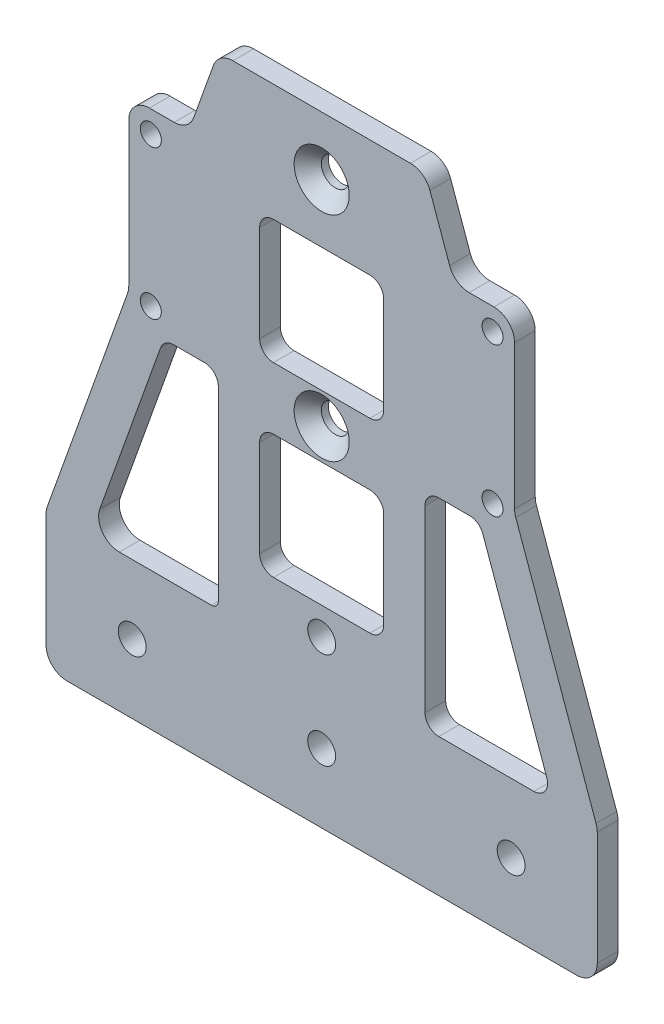
from build123d import *

# Parameters (mm, degrees)
EXTRUDE_1_DEPTH           = 1.5
SKETCH_2_W                = 18
SKETCH_2_H                = 18
CUT_EXTRUDE_1_DEPTH       = 3
FILLET_1_R                = 1
FILLET_2_R                = 2
FILLET_3_R                = 3
SKETCH_3_R                = 2.025
CUT_EXTRUDE_2_DEPTH       = 1
CUT_EXTRUDE_2_DEPTH_BACK  = 4
SKETCH_4_R                = 2.025
CUT_EXTRUDE_3_DEPTH       = 1
CUT_EXTRUDE_3_DEPTH_BACK  = 4
SKETCH_5_R                = 2.025
CUT_EXTRUDE_4_DEPTH       = 1
CUT_EXTRUDE_4_DEPTH_BACK  = 4
FILLET_4_R                = 3
EXTRUDE_2_DEPTH           = 3
FILLET_5_R                = 3
SKETCH_7_R                = 1.525
CUT_EXTRUDE_5_DEPTH       = 3
HOLE_WIZARD_1_D           = 4.05
HOLE_WIZARD_1_DEPTH       = 100
HOLE_WIZARD_1_CSINK_D     = 8
HOLE_WIZARD_1_CSINK_ANGLE = 90
FILLET_6_R                = 2


with BuildPart() as part:
    # 草图1 → 凸台-拉伸1 (new body, symmetric)
    with BuildSketch(Plane.XY):
        Polygon((40, 0), (-40, 0), (-40, 20), (-15, 90), (15, 90), (40, 20), align=None)
    extrude(amount=EXTRUDE_1_DEPTH, both=True)

    # 草图2 → 切除-拉伸1 (cut)
    with BuildSketch(Plane.XY.offset(1.5)):
        Polygon((-15, 72.160717503), (-33.62882768, 20), (-15, 20), align=None)
        with Locations((0, 64)):
            Rectangle(SKETCH_2_W, SKETCH_2_H)
        with Locations((0, 37)):
            Rectangle(SKETCH_2_W, SKETCH_2_H)
        Polygon((15, 20), (15, 72.160717503), (33.62882768, 20), align=None)
    extrude(amount=-CUT_EXTRUDE_1_DEPTH, mode=Mode.SUBTRACT)

    # 圆角1
    fillet_1_edges = [part.edges().sort_by_distance(p)[0] for p in [
        (-15, 20, 0),
        (-15, 72.160717503, 0),
    ]]
    fillet(fillet_1_edges, radius=FILLET_1_R)

    # 圆角2
    fillet_2_edges = [part.edges().sort_by_distance(p)[0] for p in [
        (-9, 46, 0),
        (-9, 28, 0),
        (9, 28, 0),
        (9, 46, 0),
        (-9, 73, 0),
        (-9, 55, 0),
        (9, 55, 0),
        (9, 73, 0),
    ]]
    fillet(fillet_2_edges, radius=FILLET_2_R)

    # 圆角3
    fillet_3_edges = [part.edges().sort_by_distance(p)[0] for p in [
        (40, 0, 0),
        (-40, 0, 0),
        (-40, 20, 0),
        (-15, 90, 0),
        (15, 90, 0),
        (40, 20, 0),
    ]]
    fillet(fillet_3_edges, radius=FILLET_3_R)

    # 草图3 → 切除-拉伸2 (cut, two sides)
    with BuildSketch(Plane.XY.offset(1.5)) as cut_extrude_2_sk:
        with Locations((-27.5, 10)):
            Circle(SKETCH_3_R)
        with Locations((27.5, 10)):
            Circle(SKETCH_3_R)
    extrude(amount=CUT_EXTRUDE_2_DEPTH, mode=Mode.SUBTRACT)
    extrude(cut_extrude_2_sk.sketch, amount=-CUT_EXTRUDE_2_DEPTH_BACK, mode=Mode.SUBTRACT)

    # 草图4 → 切除-拉伸3 (cut, two sides)
    with BuildSketch(Plane.XY.offset(1.5)) as cut_extrude_3_sk:
        with Locations((0, 10)):
            Circle(SKETCH_4_R)
    extrude(amount=CUT_EXTRUDE_3_DEPTH, mode=Mode.SUBTRACT)
    extrude(cut_extrude_3_sk.sketch, amount=-CUT_EXTRUDE_3_DEPTH_BACK, mode=Mode.SUBTRACT)

    # 草图5 → 切除-拉伸4 (cut, two sides)
    with BuildSketch(Plane.XY.offset(1.5)) as cut_extrude_4_sk:
        with Locations((0, 24)):
            Circle(SKETCH_5_R)
        with Locations((0, 50.5)):
            Circle(SKETCH_5_R)
        with Locations((0, 81.5)):
            Circle(SKETCH_5_R)
    extrude(amount=CUT_EXTRUDE_4_DEPTH, mode=Mode.SUBTRACT)
    extrude(cut_extrude_4_sk.sketch, amount=-CUT_EXTRUDE_4_DEPTH_BACK, mode=Mode.SUBTRACT)

    # 圆角4
    fillet_4_edges = [part.edges().sort_by_distance(p)[0] for p in [
        (-33.62882768, 20, 0),
    ]]
    fillet(fillet_4_edges, radius=FILLET_4_R)

    # 草图6 → 凸台-拉伸2 (add)
    with BuildSketch(Plane(origin=(0, 0, -1.5), x_dir=(-1, 0, 0), z_dir=(0, 0, -1))):
        Polygon((-28, 78), (-28, 53.6), (-19.285714286, 78), align=None)
        Polygon((28, 78), (19.285714286, 78), (28, 53.6), align=None)
        Polygon((-15, 72.160717503), (-22.914541965, 50), (-15, 50), align=None)
        with BuildLine():
            Line((15, 66.387503754), (15, 50))
            Line((15, 50), (22.914541965, 50))
            Line((22.914541965, 50), (16.941741912, 66.723840151))
            ThreePointArc((16.941741912, 66.723840151), (15.82932767, 67.372831596), (15, 66.387503754))
        make_face()
    extrude(amount=-EXTRUDE_2_DEPTH)

    # 圆角5
    fillet_5_edges = [part.edges().sort_by_distance(p)[0] for p in [
        (28, 78, 0),
        (19.285714286, 78, 0),
        (28, 53.6, 0),
        (-28, 78, 0),
        (-19.285714286, 78, 0),
        (-28, 53.6, 0),
    ]]
    fillet(fillet_5_edges, radius=FILLET_5_R)

    # 草图7 → 切除-拉伸5 (cut)
    with BuildSketch(Plane(origin=(0, 0, -1.5), x_dir=(-1, 0, 0), z_dir=(0, 0, -1))):
        with Locations((24.8, 74.8)):
            Circle(SKETCH_7_R)
        with Locations((24.8, 53.2)):
            Circle(SKETCH_7_R)
        with Locations((-24.8, 53.2)):
            Circle(SKETCH_7_R)
        with Locations((-24.8, 74.8)):
            Circle(SKETCH_7_R)
    extrude(amount=-CUT_EXTRUDE_5_DEPTH, mode=Mode.SUBTRACT)

    # 孔1
    with Locations(Plane.XY.offset(1.5)):
        with Locations((0, 81.5), (0, 50.5)):
            CounterSinkHole(HOLE_WIZARD_1_D / 2, HOLE_WIZARD_1_CSINK_D / 2, depth=HOLE_WIZARD_1_DEPTH, counter_sink_angle=HOLE_WIZARD_1_CSINK_ANGLE)

    # 圆角6
    fillet_6_edges = [part.edges().sort_by_distance(p)[0] for p in [
        (15, 50, 0),
        (22.914541965, 50, 0),
        (-22.914541965, 50, 0),
        (-15, 50, 0),
        (15, 20, 0),
        (33.62882768, 20, 0),
    ]]
    fillet(fillet_6_edges, radius=FILLET_6_R)


solid = part.part
